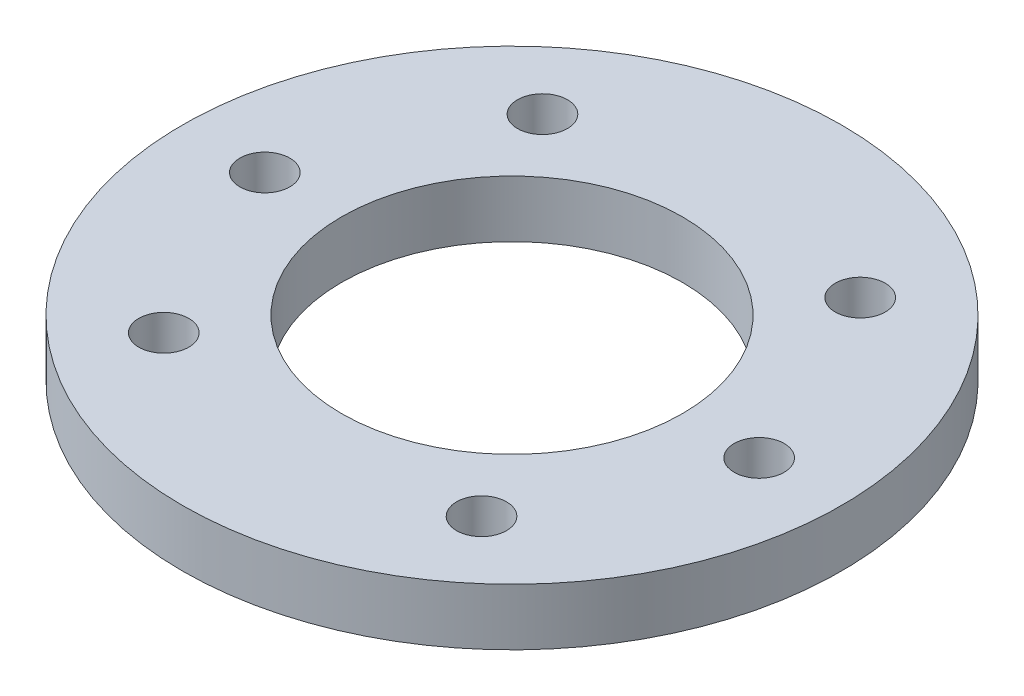
from build123d import *

# Parameters (mm, degrees)
SKETCH_1_R      = 29
SKETCH_1_R_2    = 15
SKETCH_1_R_3    = 2.2
EXTRUDE_1_DEPTH = 5


with BuildPart() as part:
    # 草图1 → 凸台-拉伸1 (new body)
    with BuildSketch(Plane(origin=(0, 0, 0), x_dir=(1, 0, 0), z_dir=(0, 1, 0))):
        Circle(SKETCH_1_R)
        Circle(SKETCH_1_R_2, mode=Mode.SUBTRACT)
        with Locations((-13.980630511, 16.661466638)):
            Circle(SKETCH_1_R_3, mode=Mode.SUBTRACT)
        with Locations((13.980630511, 16.661466638)):
            Circle(SKETCH_1_R_3, mode=Mode.SUBTRACT)
        with Locations((-21.75, 0)):
            Circle(SKETCH_1_R_3, mode=Mode.SUBTRACT)
        with Locations((21.75, 0)):
            Circle(SKETCH_1_R_3, mode=Mode.SUBTRACT)
        with Locations((13.980630511, -16.661466638)):
            Circle(SKETCH_1_R_3, mode=Mode.SUBTRACT)
        with Locations((-13.980630511, -16.661466638)):
            Circle(SKETCH_1_R_3, mode=Mode.SUBTRACT)
    extrude(amount=EXTRUDE_1_DEPTH)


solid = part.part
